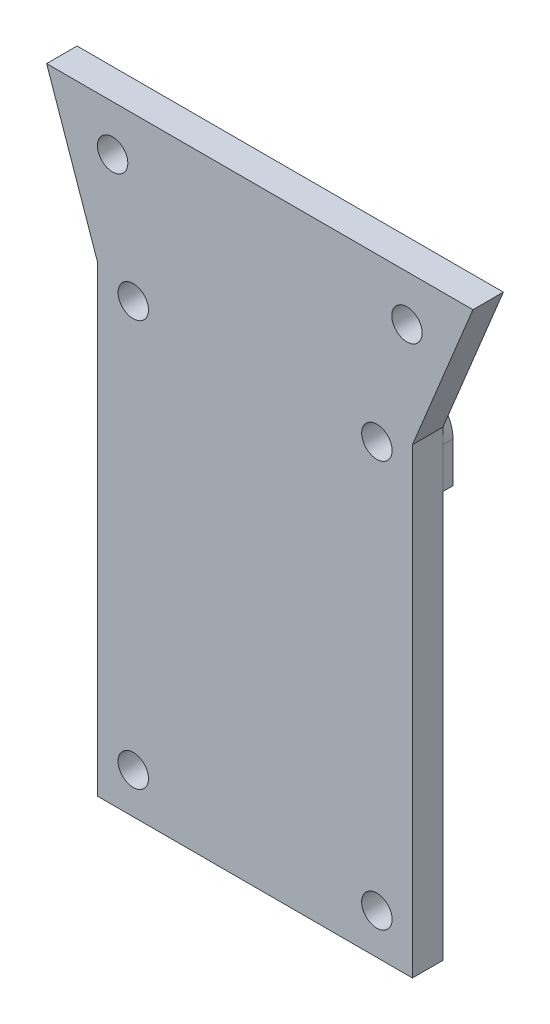
from build123d import *

# Parameters (mm, degrees)
SKETCH1_R             = 1.5
BOSS_EXTRUDE1_DEPTH   = 3
SKETCH2_R             = 2.5
BOSS_EXTRUDE2_DEPTH   = 1
BOSS_EXTRUDE2_2_DEPTH = 1
BOSS_EXTRUDE3_DEPTH   = 4
SKETCH4_W             = 4
SKETCH4_H             = 2
BOSS_EXTRUDE4_DEPTH   = 8


with BuildPart() as part:
    # Sketch1 → Boss-Extrude1 (new body)
    with BuildSketch(Plane.XY):
        Polygon((0, 0), (31, 0), (31, 45.5), (36.963007518, 60), (-5.036992482, 60), (0, 45.5), align=None)
        with Locations((30.463007518, 55.5)):
            Circle(SKETCH1_R, mode=Mode.SUBTRACT)
        with Locations((27.5, 44)):
            Circle(SKETCH1_R, mode=Mode.SUBTRACT)
        with Locations((27.5, 4)):
            Circle(SKETCH1_R, mode=Mode.SUBTRACT)
        with Locations((3.5, 4)):
            Circle(SKETCH1_R, mode=Mode.SUBTRACT)
        with Locations((3.5, 44)):
            Circle(SKETCH1_R, mode=Mode.SUBTRACT)
        with Locations((1.463007518, 55.5)):
            Circle(SKETCH1_R, mode=Mode.SUBTRACT)
    extrude(amount=BOSS_EXTRUDE1_DEPTH)


with BuildPart() as body_2:
    # Sketch2 → Boss-Extrude2 (new body)
    with BuildSketch(Plane(origin=(0, 0, 0), x_dir=(-1, 0, 0), z_dir=(0, 0, -1))):
        with BuildLine():
            Line((0, 19), (0, 44))
            ThreePointArc((0, 44), (-3.018138753, 47.466671276), (-6.86731985, 44.954545455))
            ThreePointArc((-6.86731985, 44.954545455), (-7.585457244, 43.90455193), (-8.791502622, 43.5))
            Line((-8.791502622, 43.5), (-13, 43.5))
            Line((-13, 43.5), (-13, 21))
            ThreePointArc((-13, 21), (-12.414213562, 19.585786438), (-11, 19))
            Line((-11, 19), (0, 19))
        make_face()
        with Locations((-3.5, 44)):
            Circle(SKETCH2_R, mode=Mode.SUBTRACT)
    extrude(amount=BOSS_EXTRUDE2_DEPTH)

    # Sketch3 → Boss-Extrude3 (add)
    with BuildSketch(Plane(origin=(0, 0, -1), x_dir=(-1, 0, 0), z_dir=(0, 0, -1))):
        with BuildLine():
            Line((0, 44), (0, 25.5))
            Line((0, 25.5), (-2, 25.5))
            Line((-2, 25.5), (-2, 19.5))
            Line((-2, 19.5), (-4, 19.5))
            Line((-4, 19.5), (-4, 27.5))
            Line((-4, 27.5), (-2, 27.5))
            Line((-2, 27.5), (-2, 42))
            ThreePointArc((-2, 42), (-3.5, 46.5), (-5, 42))
            Line((-5, 42), (-5, 41.5))
            Line((-5, 41.5), (-13, 41.5))
            Line((-13, 41.5), (-13, 43.5))
            Line((-13, 43.5), (-8.791502622, 43.5))
            ThreePointArc((-8.791502622, 43.5), (-7.585457244, 43.90455193), (-6.86731985, 44.954545455))
            ThreePointArc((-6.86731985, 44.954545455), (-3.018138753, 47.466671276), (0, 44))
        make_face()
    extrude(amount=BOSS_EXTRUDE3_DEPTH)



with BuildPart() as body_3:
    # Sketch2 → Boss-Extrude2 2 (new body)
    with BuildSketch(Plane(origin=(0, 0, 0), x_dir=(-1, 0, 0), z_dir=(0, 0, -1))):
        with BuildLine():
            Line((-18, 21), (-18, 43.5))
            Line((-18, 43.5), (-22.208497378, 43.5))
            ThreePointArc((-22.208497378, 43.5), (-23.414542756, 43.90455193), (-24.13268015, 44.954545455))
            ThreePointArc((-24.13268015, 44.954545455), (-27.981861247, 47.466671276), (-31, 44))
            Line((-31, 44), (-31, 40))
            add(Edge.make_bspline(
                [(-24, 19), (-24, 25.666666667), (-24.333333333, 40), (-31, 40)],
                knots=[0, 0, 0, 0, 1, 1, 1, 1], degree=3))
            Line((-24, 19), (-20, 19))
            ThreePointArc((-20, 19), (-18.585786438, 19.585786438), (-18, 21))
        make_face()
        with Locations((-27.5, 44)):
            Circle(SKETCH2_R, mode=Mode.SUBTRACT)
    extrude(amount=BOSS_EXTRUDE2_2_DEPTH)


with BuildPart() as body_2_1:
    add(body_2.part)

    add(body_3.part)  # Boss-Extrude4 merges body 3
    # Sketch4 → Boss-Extrude4 (add)
    with BuildSketch(Plane(origin=(13, 0, 0), x_dir=(0, 0, -1), z_dir=(1, 0, 0))):
        with Locations((3, 42.5)):
            Rectangle(SKETCH4_W, SKETCH4_H)
    extrude(amount=BOSS_EXTRUDE4_DEPTH)


solid = Compound([part.part, body_2_1.part])
